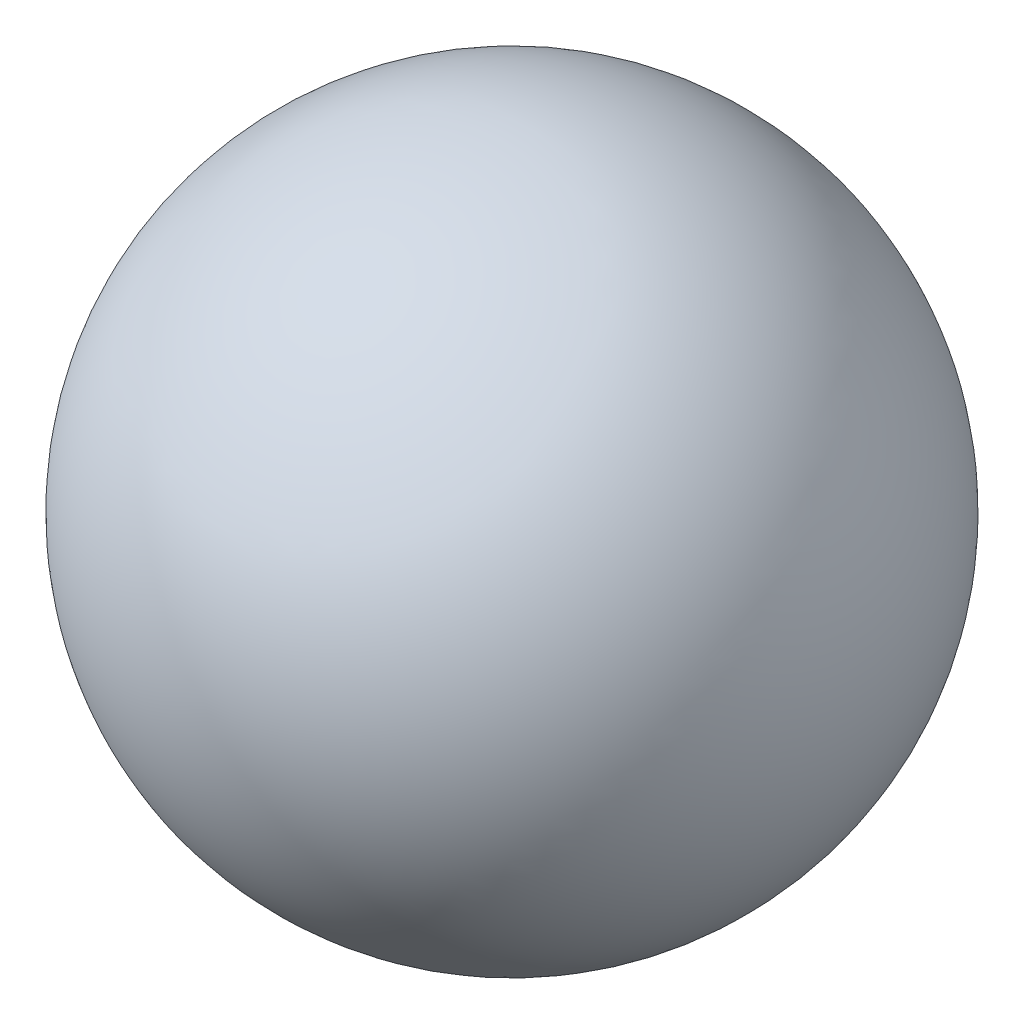
from build123d import *


with BuildPart() as part:
    # Sketch2 → Revolve1 (revolve)
    with BuildSketch(Plane(origin=(0, 0, 0), x_dir=(1, 0, 0), z_dir=(0, 1, 0))):
        with BuildLine():
            Line((0, 7.5), (0, -7.5))
            ThreePointArc((0, -7.5), (7.5, 0), (0, 7.5))
        make_face()
    revolve(axis=Axis((0, 0, -7.5), (0, 0, 1)))


solid = part.part
